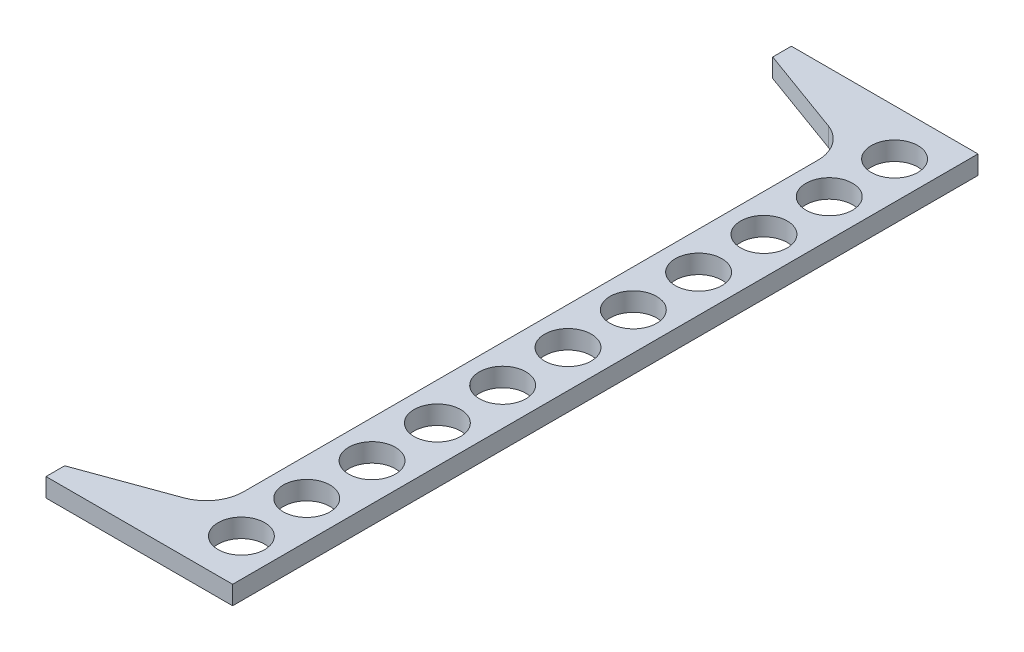
from build123d import *

# Parameters (mm, degrees)
SKETCH1_W               = 63.5
SKETCH1_H               = 6.35
BOSS_EXTRUDE1_DEPTH     = 126.8095
CUT_EXTRUDE1_DEPTH      = 1
CUT_EXTRUDE1_DEPTH_BACK = 7.35
FILLET1_R               = 12.7
LPATTERN1_COUNT         = 6
LPATTERN1_PITCH         = 22.225


with BuildPart() as part:
    # Sketch1 → Boss-Extrude1 (new body, symmetric)
    with BuildSketch(Plane.XY):
        with Locations((31.75, 3.175)):
            Rectangle(SKETCH1_W, SKETCH1_H)
    extrude(amount=BOSS_EXTRUDE1_DEPTH, both=True)

    # Sketch2 → Cut-Extrude1 (cut, two sides)
    with BuildSketch(Plane(origin=(0, 6.35, 0), x_dir=(1, 0, 0), z_dir=(0, 1, 0))) as cut_extrude1_sk:
        Polygon((-489.189690869, 298.509986386), (0, 120.4595), (38.1, 106.592234074), (38.1, -106.592234074), (0, -120.4595), (-489.189690869, -298.509986386), (-1530.359281964, -298.509986386), (-1530.359281964, 298.509986386), align=None)
    extrude(amount=CUT_EXTRUDE1_DEPTH, mode=Mode.SUBTRACT)
    extrude(cut_extrude1_sk.sketch, amount=-CUT_EXTRUDE1_DEPTH_BACK, mode=Mode.SUBTRACT)

    # Fillet1
    fillet1_edges = [part.edges().sort_by_distance(p)[0] for p in [
        (38.1, 3.175, -106.592234074),
        (38.1, 3.175, 106.592234074),
    ]]
    fillet(fillet1_edges, radius=FILLET1_R)

    # Sketch4 → 5/8 (0.625) Diameter Hole1 (revolve, cut)
    with BuildSketch(Plane(origin=(50.8, 6.35, 0), x_dir=(0, 0, 1), z_dir=(1, 0, 0))):
        Polygon((0, 0), (0, 23.819331164), (7.9375, 19.05), (7.9375, 0), align=None)
    f_5_8_0_625_diameter_hole1 = revolve(axis=Axis((50.8, 12.7, 0), (0, -1, 0)), mode=Mode.SUBTRACT)

    # LPattern1: 5/8 (0.625) Diameter Hole1 ×6
    with Locations(*[(0, 0, -i * LPATTERN1_PITCH) for i in range(1, LPATTERN1_COUNT)]):
        add(f_5_8_0_625_diameter_hole1, mode=Mode.SUBTRACT)

    # Mirror1 copy 1 sketch → Mirror1 copy 1 (revolve, cut)
    with BuildSketch(Plane(origin=(50.8, 6.35, 22.225), x_dir=(0, 0, -1), z_dir=(1, 0, 0))):
        Polygon((0, 0), (0, -23.819331164), (7.9375, -19.05), (7.9375, 0), align=None)
    revolve(axis=Axis((50.8, 12.7, 22.225), (0, 1, 0)), mode=Mode.SUBTRACT)

    # Mirror1 copy 2 sketch → Mirror1 copy 2 (revolve, cut)
    with BuildSketch(Plane(origin=(50.8, 6.35, 44.45), x_dir=(0, 0, -1), z_dir=(1, 0, 0))):
        Polygon((0, 0), (0, -23.819331164), (7.9375, -19.05), (7.9375, 0), align=None)
    revolve(axis=Axis((50.8, 12.7, 44.45), (0, 1, 0)), mode=Mode.SUBTRACT)

    # Mirror1 copy 3 sketch → Mirror1 copy 3 (revolve, cut)
    with BuildSketch(Plane(origin=(50.8, 6.35, 66.675), x_dir=(0, 0, -1), z_dir=(1, 0, 0))):
        Polygon((0, 0), (0, -23.819331164), (7.9375, -19.05), (7.9375, 0), align=None)
    revolve(axis=Axis((50.8, 12.7, 66.675), (0, 1, 0)), mode=Mode.SUBTRACT)

    # Mirror1 copy 4 sketch → Mirror1 copy 4 (revolve, cut)
    with BuildSketch(Plane(origin=(50.8, 6.35, 88.9), x_dir=(0, 0, -1), z_dir=(1, 0, 0))):
        Polygon((0, 0), (0, -23.819331164), (7.9375, -19.05), (7.9375, 0), align=None)
    revolve(axis=Axis((50.8, 12.7, 88.9), (0, 1, 0)), mode=Mode.SUBTRACT)

    # Mirror1 copy 5 sketch → Mirror1 copy 5 (revolve, cut)
    with BuildSketch(Plane(origin=(50.8, 6.35, 111.125), x_dir=(0, 0, -1), z_dir=(1, 0, 0))):
        Polygon((0, 0), (0, -23.819331164), (7.9375, -19.05), (7.9375, 0), align=None)
    revolve(axis=Axis((50.8, 12.7, 111.125), (0, 1, 0)), mode=Mode.SUBTRACT)

    # Mirror1 copy 6 sketch → Mirror1 copy 6 (revolve, cut)
    with BuildSketch(Plane(origin=(50.8, 6.35, 0), x_dir=(0, 0, -1), z_dir=(1, 0, 0))):
        Polygon((0, 0), (0, -23.819331164), (7.9375, -19.05), (7.9375, 0), align=None)
    revolve(axis=Axis((50.8, 12.7, 0), (0, 1, 0)), mode=Mode.SUBTRACT)


solid = part.part
